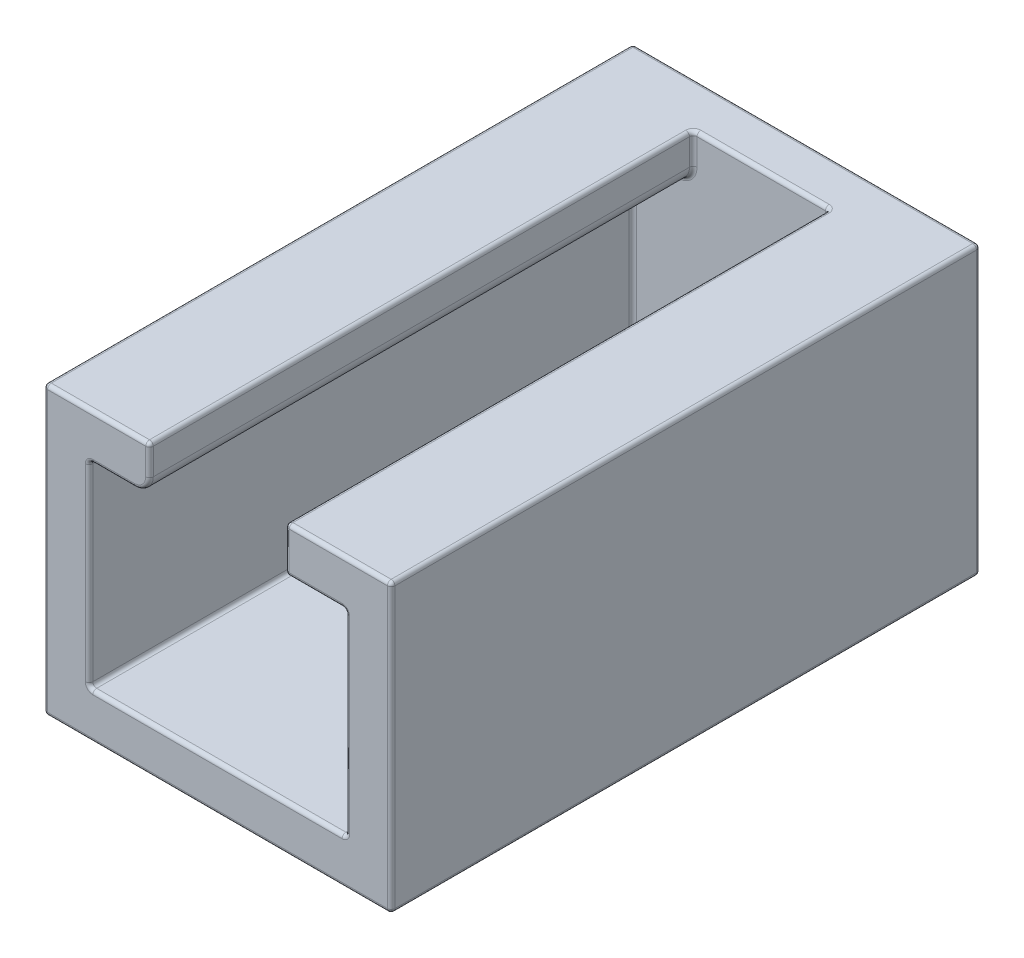
from build123d import *

# Parameters (mm, degrees)
BOSS_EXTRU_1_DEPTH = 36
ESQUISSE2_W        = 23
ESQUISSE2_H        = 19
BOSS_EXTRU_2_DEPTH = 3
CONG_1_R           = 1
CONG_2_R           = 0.25


with BuildPart() as part:
    # Esquisse1 → Boss.-Extru.1 (new body)
    with BuildSketch(Plane.XY):
        Polygon((0, 0), (23, 0), (23, 3), (23, 19), (16, 19), (16, 16), (20, 16), (20, 3), (3, 3), (3, 16), (7, 16), (7, 19), (0, 19), (0, 3), align=None)
    extrude(amount=BOSS_EXTRU_1_DEPTH)

    # Esquisse2 → Boss.-Extru.2 (add)
    with BuildSketch(Plane.XY):
        with Locations((11.5, 9.5)):
            Rectangle(ESQUISSE2_W, ESQUISSE2_H)
    extrude(amount=-BOSS_EXTRU_2_DEPTH)

    # Congé1
    cong_1_edges = [part.edges().sort_by_distance(p)[0] for p in [
        (7, 16, 18),
    ]]
    fillet(cong_1_edges, radius=CONG_1_R)

    # Congé2
    cong_2_edges = [part.edges().sort_by_distance(p)[0] for p in [
        (19.5, 19, 36),
        (16, 17.5, 36),
        (4.5, 16, 0),
        (3, 9.5, 0),
        (11.5, 3, 0),
        (20, 9.5, 0),
        (18, 16, 36),
        (18, 16, 0),
        (16, 17.5, 0),
        (20, 9.5, 36),
        (11.5, 3, 36),
        (23, 0, 16.5),
        (0, 0, 16.5),
        (0, 19, 16.5),
        (7, 19, 18),
        (3, 16, 18),
        (3, 3, 18),
        (20, 3, 18),
        (20, 16, 18),
        (16, 16, 18),
        (16, 19, 18),
        (23, 19, 16.5),
        (3, 9.5, 36),
        (4.5, 16, 36),
        (3.5, 19, 36),
        (0, 9.5, 36),
        (23, 9.5, 36),
        (23, 9.5, -3),
        (11.5, 0, -3),
        (0, 9.5, -3),
        (11.5, 19, -3),
        (11.5, 19, 0),
        (11.5, 0, 36),
        (7, 18, 0),
        (7, 18, 36),
        (6.707106781, 16.292893219, 36),
        (6.707106781, 16.292893219, 0),
    ]]
    fillet(cong_2_edges, radius=CONG_2_R)


solid = part.part
